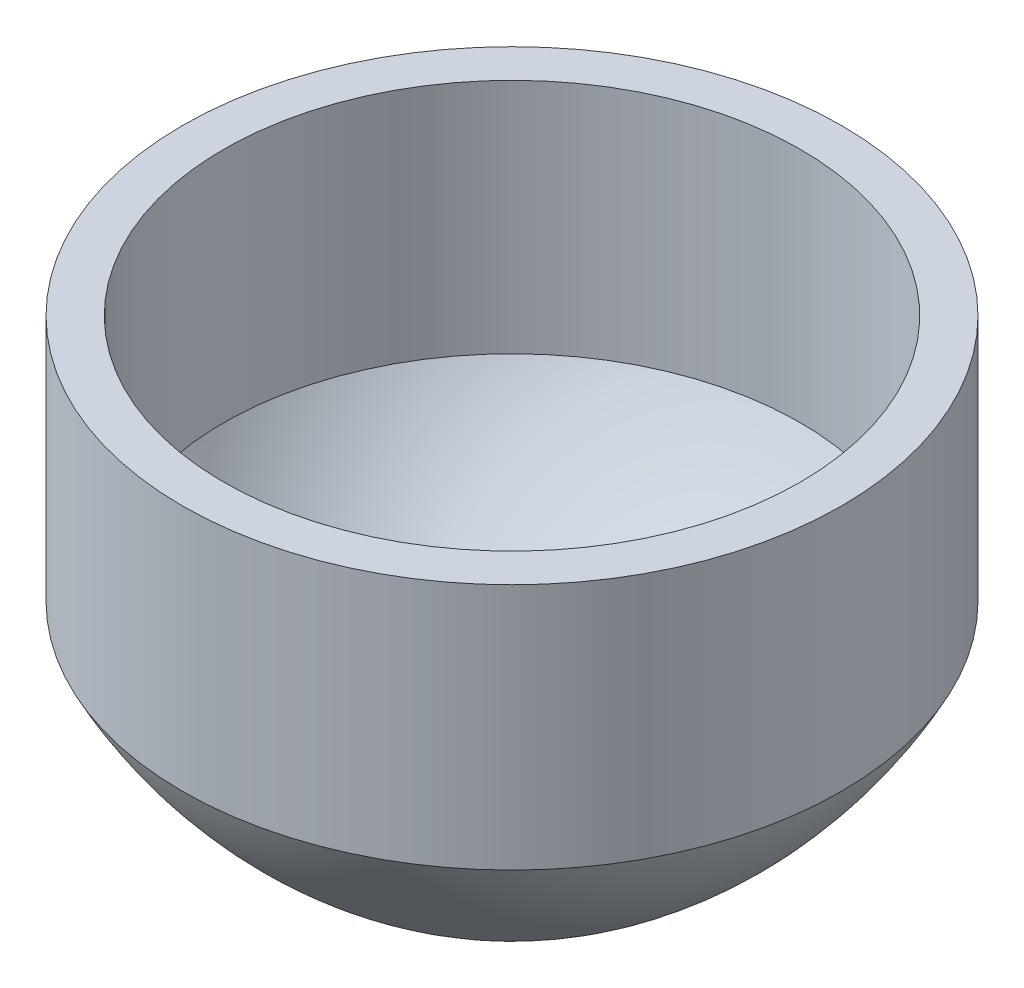
from build123d import *


with BuildPart() as part:
    # Sketch1 → Revolve1 (revolve)
    with BuildSketch(Plane.XY):
        with BuildLine():
            Line((1400, 0), (1600, 0))
            Line((1600, 0), (1600, -1200))
            ThreePointArc((1600, -1200), (937.095696626, -1968.099128692), (0, -2357.033624837))
            Line((0, -2357.033624837), (0, -2154.155430565))
            ThreePointArc((0, -2154.155430565), (813.687097889, -1810.508559906), (1400, -1149.88987579))
            Line((1400, -1149.88987579), (1400, 0))
        make_face()
    revolve(axis=Axis((0, -1000, 0), (0, 1, 0)))


solid = part.part
